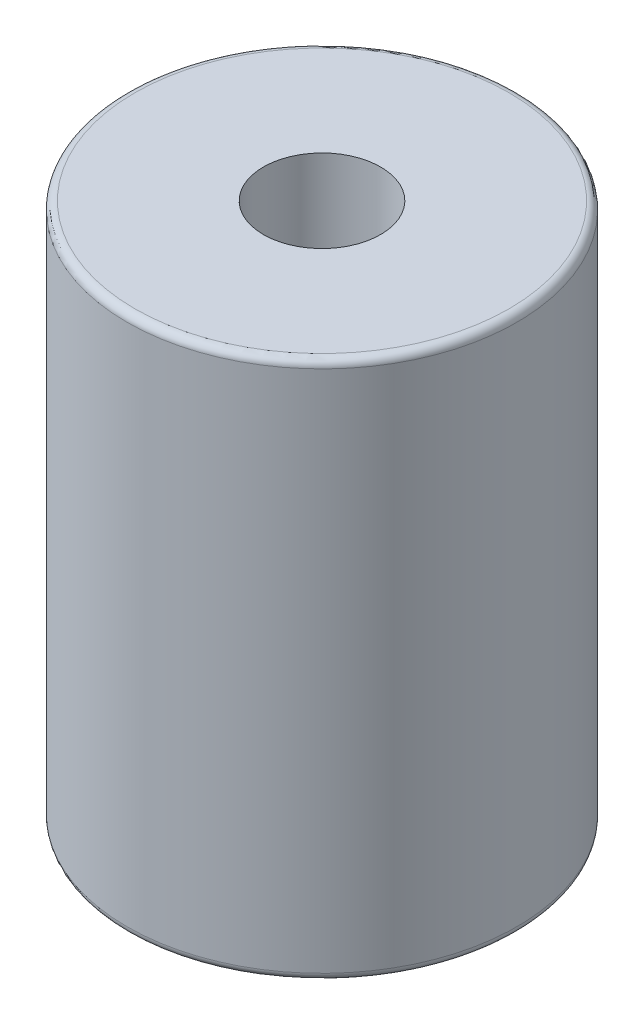
from build123d import *

# Parameters (mm, degrees)
CROQUIS1_R              = 2.495
SALIENTE_EXTRUIR1_DEPTH = 6.9
REDONDEO1_R             = 0.1
CROQUIS2_R              = 0.75
CORTAR_EXTRUIR1_DEPTH   = 3


with BuildPart() as part:
    # Croquis1 → Saliente-Extruir1 (new body)
    with BuildSketch(Plane(origin=(0, 0, 0), x_dir=(1, 0, 0), z_dir=(0, 1, 0))):
        Circle(CROQUIS1_R)
    extrude(amount=SALIENTE_EXTRUIR1_DEPTH)

    # Redondeo1
    redondeo1_edges = [part.edges().sort_by_distance(p)[0] for p in [
        (-2.495, 0, 0),
        (-2.495, 6.9, 0),
    ]]
    fillet(redondeo1_edges, radius=REDONDEO1_R)

    # Croquis2 → Cortar-Extruir1 (cut)
    with BuildSketch(Plane(origin=(0, 6.9, 0), x_dir=(1, 0, 0), z_dir=(0, 1, 0))):
        Circle(CROQUIS2_R)
    extrude(amount=-CORTAR_EXTRUIR1_DEPTH, mode=Mode.SUBTRACT)


solid = part.part
